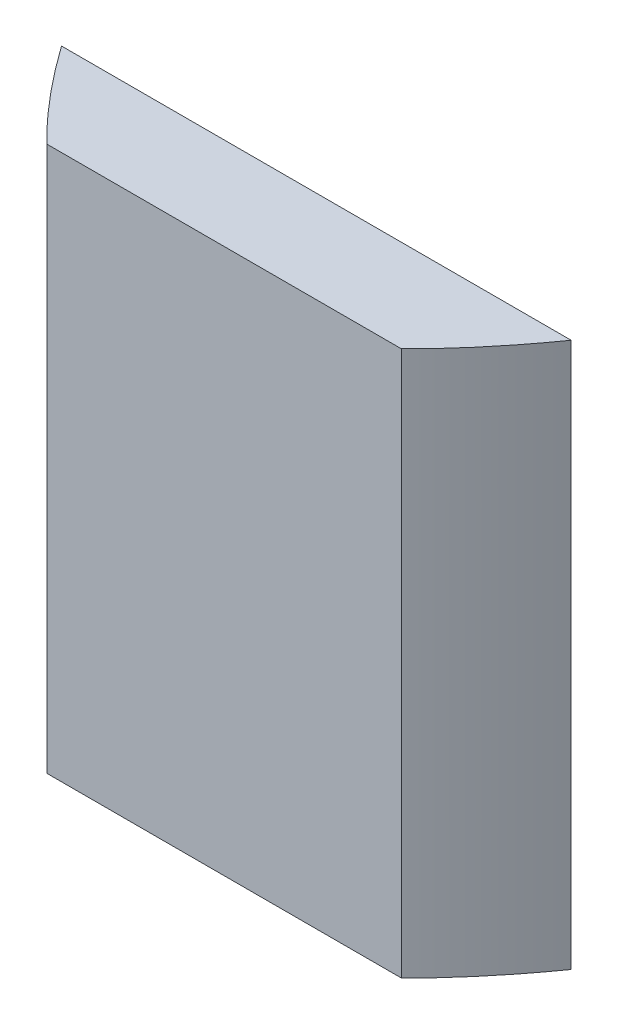
from build123d import *

# Parameters (mm, degrees)
BOSS_EXTRUDE1_DEPTH = 300
SKETCH2_W           = 518.16192396
SKETCH2_H           = 180.558136174
CUT_EXTRUDE1_DEPTH  = 350
SKETCH3_W           = 500.860284375
SKETCH3_H           = 116.675159248
CUT_EXTRUDE2_DEPTH  = 350


with BuildPart() as part:
    # Sketch1 → Boss-Extrude1 (new body)
    with BuildSketch(Plane(origin=(0, 0, 0), x_dir=(1, 0, 0), z_dir=(0, 1, 0))):
        with BuildLine():
            Line((-200, 1e-09), (200, 1e-09))
            add(Edge.make_bspline(
                [(-200, 1e-09), (0, -400.000000001), (200, 1e-09)],
                knots=[0.056028396, 0.056028396, 0.056028396, 0.943971604, 0.943971604, 0.943971604], degree=2))
        make_face()
    extrude(amount=BOSS_EXTRUDE1_DEPTH)

    # Sketch2 → Cut-Extrude1 (cut)
    with BuildSketch(Plane(origin=(0, 300, 0), x_dir=(1, 0, 0), z_dir=(0, 1, 0))):
        with Locations((17.079823692, -11.320931912)):
            Rectangle(SKETCH2_W, SKETCH2_H)
    extrude(amount=-CUT_EXTRUDE1_DEPTH, mode=Mode.SUBTRACT)

    # Sketch3 → Cut-Extrude2 (cut)
    with BuildSketch(Plane(origin=(0, 300, 0), x_dir=(1, 0, 0), z_dir=(0, 1, 0))):
        with Locations((15.970744232, -210.737579623)):
            Rectangle(SKETCH3_W, SKETCH3_H)
    extrude(amount=-CUT_EXTRUDE2_DEPTH, mode=Mode.SUBTRACT)


solid = part.part
